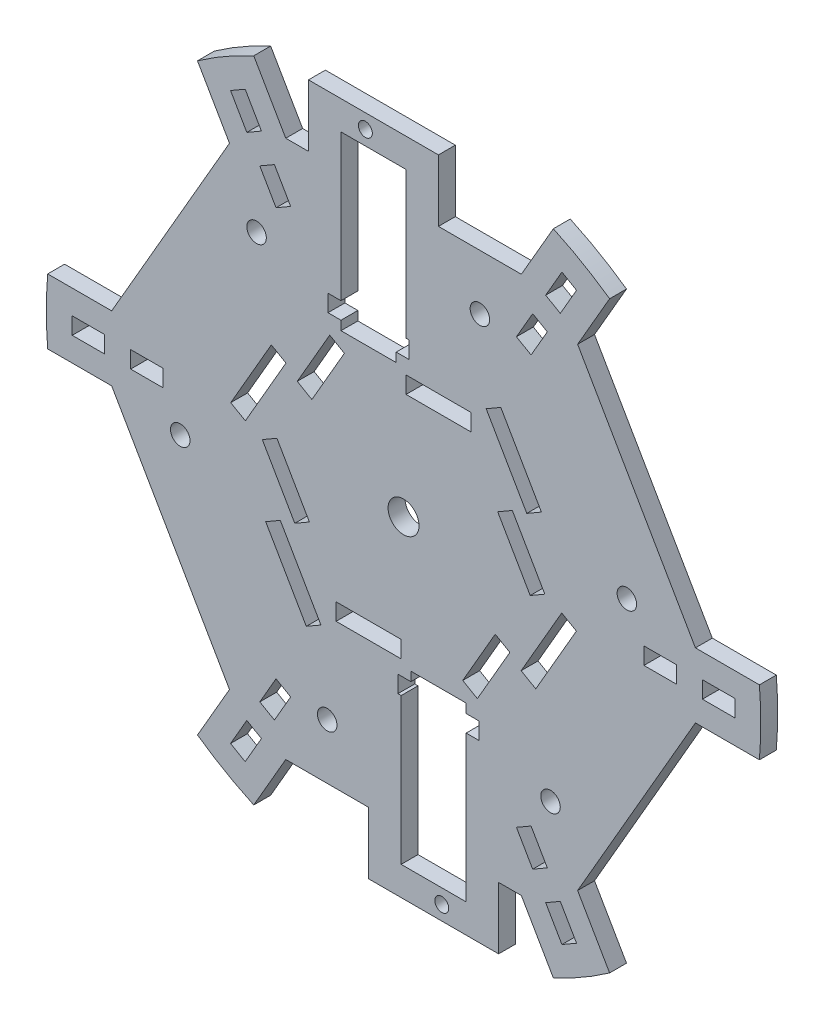
from build123d import *

# Parameters (mm, degrees)
SKETCH1_R                   = 110
SKETCH1_R_2                 = 4.7625
BOSS_EXTRUDE1_DEPTH         = 2.6
SKETCH2_R                   = 2.15
CUT_EXTRUDE3_DEPTH          = 6.2
CIRPATTERN1_COUNT           = 2
CIRPATTERN2_COUNT           = 2
CIRPATTERN2_ANGLE           = 60
CIRPATTERN2_COPY_1_SKETCH_R = 2.15
CIRPATTERN2_COPY_1_DEPTH    = 6.2
CUT_EXTRUDE5_DEPTH          = 6.2
SKETCH11_R                  = 3
SKETCH11_W                  = 25
SKETCH11_H                  = 5.2
CUT_EXTRUDE24_DEPTH         = 6.2
CUT_EXTRUDE25_DEPTH         = 6.2
CUT_EXTRUDE26_DEPTH         = 6.2


with BuildPart() as part:
    # Sketch1 → Boss-Extrude1 (new body, symmetric)
    with BuildSketch(Plane.XY):
        Circle(SKETCH1_R)
        Circle(SKETCH1_R_2, mode=Mode.SUBTRACT)
        Polygon((-4.7625, 40), (-2.2625, 40), (-2.2625, 48), (0.7375, 48), (0.7375, 93), (-19.2625, 93), (-19.2625, 40), (-16.7625, 40), align=None, mode=Mode.SUBTRACT)
        Polygon((4.7625, -40), (2.2625, -40), (2.2625, -48), (-0.7375, -48), (-0.7375, -93), (19.2625, -93), (19.2625, -40), (16.7625, -40), align=None, mode=Mode.SUBTRACT)
    extrude(amount=BOSS_EXTRUDE1_DEPTH, both=True)

    # Sketch2 → Cut-Extrude3 (cut, through all)
    with BuildSketch(Plane.XY.offset(2.6)):
        with Locations((11.7625, -97.435)):
            Circle(SKETCH2_R)
        with BuildLine():
            Line((-10.7375, -82.808492409), (-10.7375, -101.8725))
            Line((-10.7375, -101.8725), (9.2625, -101.8725))
            Line((9.2625, -101.8725), (29.2625, -101.8725))
            Line((29.2625, -101.8725), (29.2625, -82.808492409))
            Line((29.2625, -82.808492409), (36.2625, -82.808492409))
            Line((36.2625, -82.808492409), (46.112001713, -99.868329805))
            ThreePointArc((46.112001713, -99.868329805), (0, -110), (-46.112001713, -99.868329805))
            Line((-46.112001713, -99.868329805), (-36.2625, -82.808492409))
            Line((-36.2625, -82.808492409), (-10.7375, -82.808492409))
        make_face()
    cut_extrude3 = extrude(amount=-CUT_EXTRUDE3_DEPTH, mode=Mode.SUBTRACT)

    # CirPattern1: Cut-Extrude3 ×2 about axis
    cirpattern1_axis = Axis((0, 0, 0), (0, 0, 1))
    for i in range(1, CIRPATTERN1_COUNT):
        add(cut_extrude3.rotate(cirpattern1_axis, i * 360 / CIRPATTERN1_COUNT), mode=Mode.SUBTRACT)

    # CirPattern2: Cut-Extrude3 ×2 about axis
    cirpattern2_axis = Axis((0, 0, 0), (0, 0, 1))
    for i in range(1, CIRPATTERN2_COUNT):
        add(cut_extrude3.rotate(cirpattern2_axis, i * CIRPATTERN2_ANGLE / (CIRPATTERN2_COUNT - 1)), mode=Mode.SUBTRACT)

    # CirPattern2 copy 1 sketch → CirPattern2 copy 1 (cut, through all)
    with BuildSketch(Plane(origin=(0, 0, 2.6), x_dir=(-0.5, -0.866025404, 0), z_dir=(0, 0, 1))):
        with Locations((11.7625, -97.435)):
            Circle(CIRPATTERN2_COPY_1_SKETCH_R)
        with BuildLine():
            Line((-10.7375, -82.808492409), (-10.7375, -101.8725))
            Line((-10.7375, -101.8725), (9.2625, -101.8725))
            Line((9.2625, -101.8725), (29.2625, -101.8725))
            Line((29.2625, -101.8725), (29.2625, -82.808492409))
            Line((29.2625, -82.808492409), (36.2625, -82.808492409))
            Line((36.2625, -82.808492409), (46.112001713, -99.868329805))
            ThreePointArc((46.112001713, -99.868329805), (0, -110), (-46.112001713, -99.868329805))
            Line((-46.112001713, -99.868329805), (-36.2625, -82.808492409))
            Line((-36.2625, -82.808492409), (-10.7375, -82.808492409))
        make_face()
    extrude(amount=-CIRPATTERN2_COPY_1_DEPTH, mode=Mode.SUBTRACT)

    # Sketch5 → Cut-Extrude5 (cut, through all)
    with BuildSketch(Plane.XY.offset(2.6)):
        with BuildLine():
            Line((89.845508076, 10), (53.583008076, 72.808492409))
            Line((53.583008076, 72.808492409), (63.432509788, 89.868329805))
            ThreePointArc((63.432509788, 89.868329805), (95.262794416, 55), (109.544511501, 10))
            Line((109.544511501, 10), (89.845508076, 10))
        make_face()
        with BuildLine():
            Line((-89.845508076, -10), (-53.583008076, -72.808492409))
            Line((-53.583008076, -72.808492409), (-63.432509788, -89.868329805))
            ThreePointArc((-63.432509788, -89.868329805), (-95.262794416, -55), (-109.544511501, -10))
            Line((-109.544511501, -10), (-89.845508076, -10))
        make_face()
    extrude(amount=-CUT_EXTRUDE5_DEPTH, mode=Mode.SUBTRACT)

    # Sketch11 → Cut-Extrude24 (cut, through all)
    with BuildSketch(Plane.XY.offset(2.6)):
        with Locations((45.241826211, -53.255843194)):
            Circle(SKETCH11_R)
        with Locations((-23.5, -65.808492409)):
            Circle(SKETCH11_R)
        with Locations((-68.741826211, -12.552649216)):
            Circle(SKETCH11_R)
        with Locations((-45.241826211, 53.255843194)):
            Circle(SKETCH11_R)
        with Locations((23.5, 65.808492409)):
            Circle(SKETCH11_R)
        with Locations((68.741826211, 12.552649216)):
            Circle(SKETCH11_R)
        Polygon((-1.7375, -48), (23.2625, -48), (23.2625, -42.8), (19.2625, -42.8), (2.2625, -42.8), (-1.7375, -42.8), align=None)
        Polygon((-42.437969382, -22.495280861), (-29.937969382, -44.145915956), (-25.434637282, -41.545915956), (-37.934637282, -19.895280861), align=None)
        Polygon((-20.7625, -33.025), (-16.7625, -33.025), (-4.7625, -33.025), (-0.7625, -33.025), (-0.7625, -38.225), (-20.7625, -38.225), align=None)
        Polygon((-38.98173896, 1.468352446), (-36.98173896, -1.995749169), (-30.98173896, -12.388054014), (-28.98173896, -15.85215563), (-33.48507106, -18.45215563), (-43.48507106, -1.131647554), align=None)
        Polygon((-40.700469382, 25.504719139), (-53.200469382, 3.854084044), (-48.697137282, 1.254084044), (-36.197137282, 22.904719139), align=None)
        Polygon((-18.21923896, 34.493352446), (-20.21923896, 31.029250831), (-26.21923896, 20.636945986), (-28.21923896, 17.17284437), (-32.72257106, 19.77284437), (-22.72257106, 37.093352446), align=None)
        with Locations((-10.7625, 45.4)):
            Rectangle(SKETCH11_W, SKETCH11_H)
        Polygon((42.437969382, 22.495280861), (29.937969382, 44.145915956), (25.434637282, 41.545915956), (37.934637282, 19.895280861), align=None)
        Polygon((20.7625, 33.025), (16.7625, 33.025), (4.7625, 33.025), (0.7625, 33.025), (0.7625, 38.225), (20.7625, 38.225), align=None)
        Polygon((40.700469382, -25.504719139), (53.200469382, -3.854084044), (48.697137282, -1.254084044), (36.197137282, -22.904719139), align=None)
        Polygon((38.98173896, -1.468352446), (36.98173896, 1.995749169), (30.98173896, 12.388054014), (28.98173896, 15.85215563), (33.48507106, 18.45215563), (43.48507106, 1.131647554), align=None)
        Polygon((18.21923896, -34.493352446), (20.21923896, -31.029250831), (26.21923896, -20.636945986), (28.21923896, -17.17284437), (32.72257106, -19.77284437), (22.72257106, -37.093352446), align=None)
    extrude(amount=-CUT_EXTRUDE24_DEPTH, mode=Mode.SUBTRACT)

    # Sketch12 → Cut-Extrude25 (cut, through all)
    with BuildSketch(Plane.XY.offset(2.6)):
        Polygon((-37, -64.08587988), (-34.74833395, -65.38587988), (-39.74833395, -74.046133918), (-44.25166605, -71.446133918), (-39.25166605, -62.78587988), align=None)
        Polygon((-51, -88.334591186), (-48.74833395, -89.634591186), (-43.74833395, -80.974337148), (-48.25166605, -78.374337148), (-53.25166605, -87.034591186), align=None)
        Polygon((-74, 0), (-74, -2.6), (-84, -2.6), (-84, 2.6), (-74, 2.6), align=None)
        Polygon((-102, 0), (-102, -2.6), (-92, -2.6), (-92, 2.6), (-102, 2.6), align=None)
        Polygon((-37, 64.08587988), (-39.25166605, 62.78587988), (-44.25166605, 71.446133918), (-39.74833395, 74.046133918), (-34.74833395, 65.38587988), align=None)
        Polygon((-51, 88.334591186), (-53.25166605, 87.034591186), (-48.25166605, 78.374337148), (-43.74833395, 80.974337148), (-48.74833395, 89.634591186), align=None)
        Polygon((37, 64.08587988), (34.74833395, 65.38587988), (39.74833395, 74.046133918), (44.25166605, 71.446133918), (39.25166605, 62.78587988), align=None)
        Polygon((51, 88.334591186), (48.74833395, 89.634591186), (43.74833395, 80.974337148), (48.25166605, 78.374337148), (53.25166605, 87.034591186), align=None)
        Polygon((74, 0), (74, 2.6), (84, 2.6), (84, -2.6), (74, -2.6), align=None)
        Polygon((102, 0), (102, 2.6), (92, 2.6), (92, -2.6), (102, -2.6), align=None)
        Polygon((37, -64.08587988), (39.25166605, -62.78587988), (44.25166605, -71.446133918), (39.74833395, -74.046133918), (34.74833395, -65.38587988), align=None)
        Polygon((51, -88.334591186), (53.25166605, -87.034591186), (48.25166605, -78.374337148), (43.74833395, -80.974337148), (48.74833395, -89.634591186), align=None)
    extrude(amount=-CUT_EXTRUDE25_DEPTH, mode=Mode.SUBTRACT)

    # Sketch13 → Cut-Extrude26 (cut, through all)
    with BuildSketch(Plane.XY.offset(2.6)):
        Polygon((-86.345508076, 16.062177826), (-66.345508076, 50.703193978), (-76.345508076, 67.59574596), (-92.560678517, 57.996740162), (-113.304387557, 22.067582168), align=None)
        Polygon((66.345508076, -50.703193978), (83.10535709, -79.014856047), (116.539469578, -32.259052148), (108.045386829, -17.910378712), (86.345508076, -16.062177826), align=None)
    extrude(amount=-CUT_EXTRUDE26_DEPTH, mode=Mode.SUBTRACT)


solid = part.part
